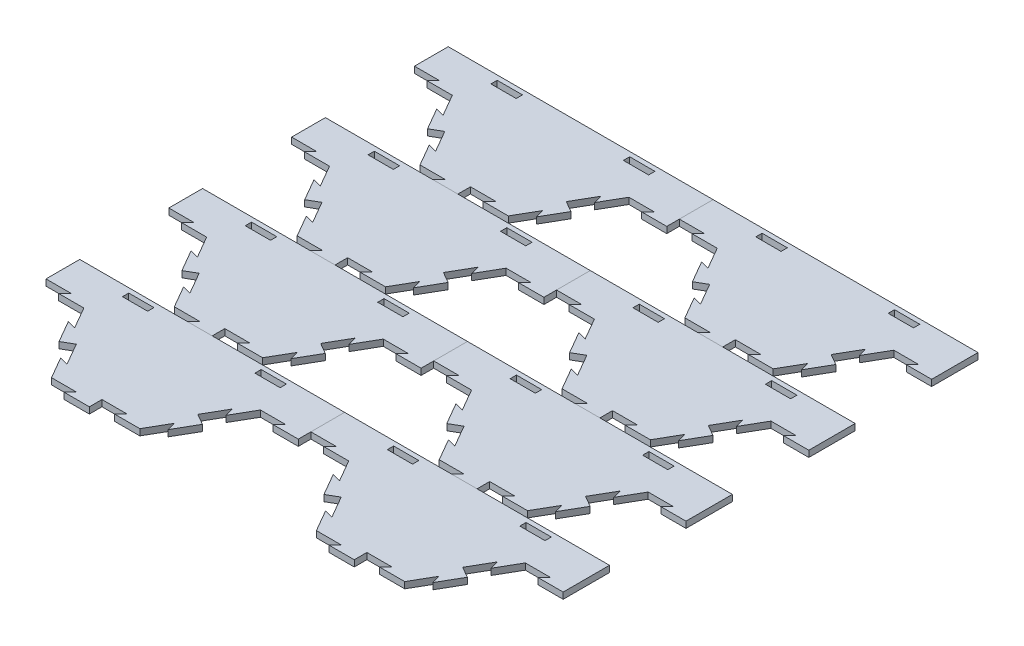
from build123d import *

# Parameters (mm, degrees)
BOSS_EXTRUDE1_DEPTH = 6.35
CUT_EXTRUDE4_DEPTH  = 7.35
BOSS_EXTRUDE4_DEPTH = 6.35
CIRPATTERN7_COUNT   = 6
SKETCH12_W          = 177.8
SKETCH12_H          = 83.339658396
CUT_EXTRUDE5_DEPTH  = 7.35
SKETCH13_W          = 266.7
SKETCH13_H          = 6.35
BOSS_EXTRUDE5_DEPTH = 40.327916296
CUT_EXTRUDE6_DEPTH  = 7.35
BOSS_EXTRUDE6_DEPTH = 6.35
SKETCH17_W          = 25.4
SKETCH17_H          = 6.35
CUT_EXTRUDE8_DEPTH  = 7.35
LPATTERN1_COUNT     = 2
LPATTERN1_PITCH     = 266.7
LPATTERN2_COUNT     = 4
LPATTERN2_PITCH     = 123.66757461


with BuildPart() as part:
    # Sketch1 → Boss-Extrude1 (new body)
    with BuildSketch(Plane(origin=(0, 0, 0), x_dir=(1, 0, 0), z_dir=(0, 1, 0))):
        Polygon((88.9, 0), (44.45, 76.989658396), (-44.45, 76.989658396), (-88.9, 0), (-44.45, -76.989658396), (44.45, -76.989658396), align=None)
    extrude(amount=-BOSS_EXTRUDE1_DEPTH)

    # Sketch10 → Cut-Extrude4 (cut, through all)
    with BuildSketch(Plane(origin=(0, 0, 0), x_dir=(1, 0, 0), z_dir=(0, 1, 0))):
        Polygon((57.15, 54.99261314), (48.475738686, 57.316874454), (61.175738686, 35.319829198), (66.675, 38.494829198), align=None)
    cut_extrude4 = extrude(amount=-CUT_EXTRUDE4_DEPTH, mode=Mode.SUBTRACT)

    # Sketch11 → Boss-Extrude4 (add)
    with BuildSketch(Plane(origin=(0, 0, 0), x_dir=(1, 0, 0), z_dir=(0, 1, 0))):
        Polygon((66.675, 38.494829198), (72.174261314, 41.669829198), (84.874261314, 19.672783942), (76.2, 21.997045256), align=None)
    boss_extrude4 = extrude(amount=-BOSS_EXTRUDE4_DEPTH)

    # CirPattern7: Cut-Extrude4, Boss-Extrude4 ×6 about axis
    cirpattern7_axis = Axis((0, 0, 0), (0, 1, 0))
    for i in range(1, CIRPATTERN7_COUNT):
        add(cut_extrude4.rotate(cirpattern7_axis, i * 360 / CIRPATTERN7_COUNT), mode=Mode.SUBTRACT)
        add(boss_extrude4.rotate(cirpattern7_axis, i * 360 / CIRPATTERN7_COUNT))

    # Sketch12 → Cut-Extrude5 (cut, through all)
    with BuildSketch(Plane(origin=(0, 0, 0), x_dir=(1, 0, 0), z_dir=(0, 1, 0))):
        with Locations((0, 41.669829198)):
            Rectangle(SKETCH12_W, SKETCH12_H)
    extrude(amount=-CUT_EXTRUDE5_DEPTH, mode=Mode.SUBTRACT)

    # Sketch13 → Boss-Extrude5 (add)
    with BuildSketch(Plane(origin=(0, 0, 0), x_dir=(-1, 0, 0), z_dir=(0, 0, -1))):
        with Locations((0, -3.175)):
            Rectangle(SKETCH13_W, SKETCH13_H)
    extrude(amount=BOSS_EXTRUDE5_DEPTH)

    # Sketch15 → Cut-Extrude6 (cut, through all)
    with BuildSketch(Plane(origin=(0, 0, 0), x_dir=(1, 0, 0), z_dir=(0, 1, 0))):
        Polygon((-114.3, 0), (-107.95, 6.35), (-133.35, 6.35), (-133.35, 0), align=None)
    extrude(amount=-CUT_EXTRUDE6_DEPTH, mode=Mode.SUBTRACT)

    # Sketch16 → Boss-Extrude6 (add)
    with BuildSketch(Plane(origin=(0, 0, 0), x_dir=(1, 0, 0), z_dir=(0, 1, 0))):
        Polygon((114.3, 0), (107.95, -6.35), (133.35, -6.35), (133.35, 0), align=None)
    extrude(amount=-BOSS_EXTRUDE6_DEPTH)

    # Sketch17 → Cut-Extrude8 (cut, through all)
    with BuildSketch(Plane(origin=(0, 0, 0), x_dir=(1, 0, 0), z_dir=(0, 1, 0))):
        with Locations((-66.675, 32.504390033)):
            Rectangle(SKETCH17_W, SKETCH17_H)
        with Locations((66.675, 32.504390033)):
            Rectangle(SKETCH17_W, SKETCH17_H)
    extrude(amount=-CUT_EXTRUDE8_DEPTH, mode=Mode.SUBTRACT)


with BuildPart() as lpattern1_1:
    # LPattern1: pattern copy
    add(part.part.moved(Location(Vector(1, 0, 0) * (1 * LPATTERN1_PITCH))))


with BuildPart() as lpattern2_1:
    # LPattern2: pattern copy
    add(part.part.moved(Location(Vector(0, 0, 1) * (1 * LPATTERN2_PITCH))))


with BuildPart() as lpattern2_2:
    # LPattern2: pattern copy
    add(part.part.moved(Location(Vector(0, 0, 1) * (2 * LPATTERN2_PITCH))))


with BuildPart() as lpattern2_3:
    # LPattern2: pattern copy
    add(part.part.moved(Location(Vector(0, 0, 1) * (3 * LPATTERN2_PITCH))))


with BuildPart() as lpattern2_4:
    # LPattern2: pattern copy
    add(lpattern1_1.part.moved(Location(Vector(0, 0, 1) * (1 * LPATTERN2_PITCH))))


with BuildPart() as lpattern2_5:
    # LPattern2: pattern copy
    add(lpattern1_1.part.moved(Location(Vector(0, 0, 1) * (2 * LPATTERN2_PITCH))))


with BuildPart() as lpattern2_6:
    # LPattern2: pattern copy
    add(lpattern1_1.part.moved(Location(Vector(0, 0, 1) * (3 * LPATTERN2_PITCH))))


solid = Compound([part.part, lpattern1_1.part, lpattern2_1.part, lpattern2_2.part, lpattern2_3.part, lpattern2_4.part, lpattern2_5.part, lpattern2_6.part])
